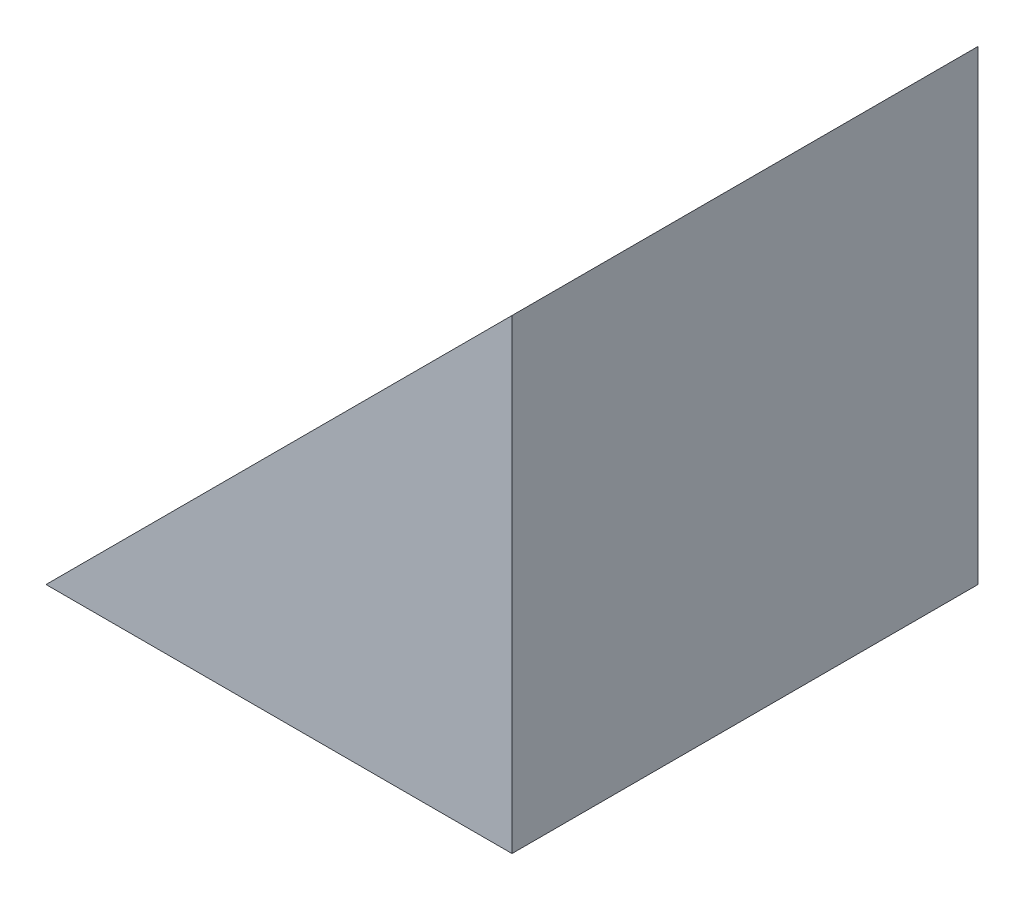
from build123d import *

# Parameters (mm, degrees)
EXTRUDE_1_DEPTH = 12.5


with BuildPart() as part:
    # 草图1 → 凸台-拉伸1 (new body)
    with BuildSketch(Plane.XY):
        Polygon((43.678515928, 33.19476756), (43.678515928, 45.69476756), (31.178515928, 33.19476756), align=None)
    extrude(amount=EXTRUDE_1_DEPTH)


solid = part.part
